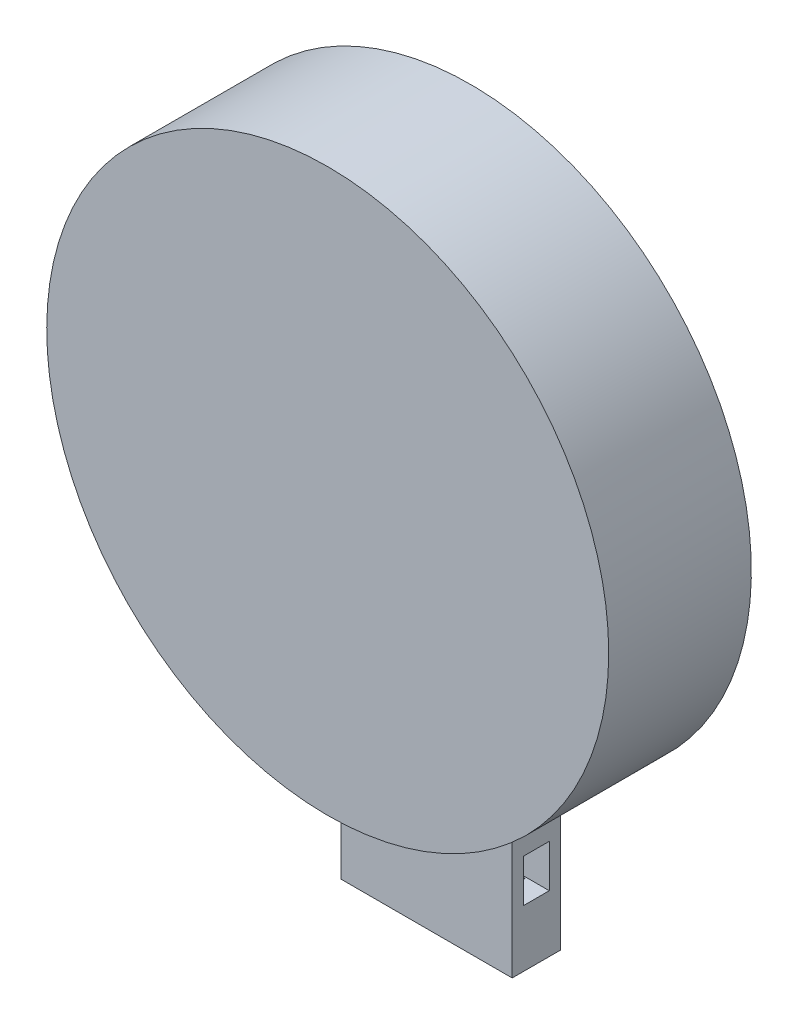
from build123d import *

# Parameters (mm, degrees)
SKETCH1_R           = 98.505410199
BOSS_EXTRUDE1_DEPTH = 50
BOSS_EXTRUDE2_START = -5.228497
SKETCH2_W           = 60
SKETCH2_H           = 17
BOSS_EXTRUDE2_DEPTH = 55.228497
SKETCH3_W           = 44
SKETCH3_H           = 8
CUT_EXTRUDE1_DEPTH  = 40
SKETCH4_W           = 9
SKETCH4_H           = 15
CUT_EXTRUDE2_DEPTH  = 127.839445164


with BuildPart() as part:
    # Sketch1 → Boss-Extrude1 (new body)
    with BuildSketch(Plane.XY):
        Circle(SKETCH1_R)
    extrude(amount=BOSS_EXTRUDE1_DEPTH)

    # Sketch2 → Boss-Extrude2 (add)
    with BuildSketch(Plane(origin=(0, -98.505410199, 0), x_dir=(-1, 0, 0), z_dir=(0, -1, 0)).offset(BOSS_EXTRUDE2_START)):
        with Locations((-1.665965035, -8.5)):
            Rectangle(SKETCH2_W, SKETCH2_H)
    extrude(amount=BOSS_EXTRUDE2_DEPTH)

    # Sketch3 → Cut-Extrude1 (cut)
    with BuildSketch(Plane.XZ.offset(148.505410199)):
        with Locations((1.665965035, 8.5)):
            Rectangle(SKETCH3_W, SKETCH3_H)
    extrude(amount=-CUT_EXTRUDE1_DEPTH, mode=Mode.SUBTRACT)

    # Sketch4 → Cut-Extrude2 (cut, through all)
    with BuildSketch(Plane.ZY.offset(28.334034965)):
        with Locations((8.5, -121.005410199)):
            Rectangle(SKETCH4_W, SKETCH4_H)
    extrude(amount=-CUT_EXTRUDE2_DEPTH, mode=Mode.SUBTRACT)


solid = part.part
